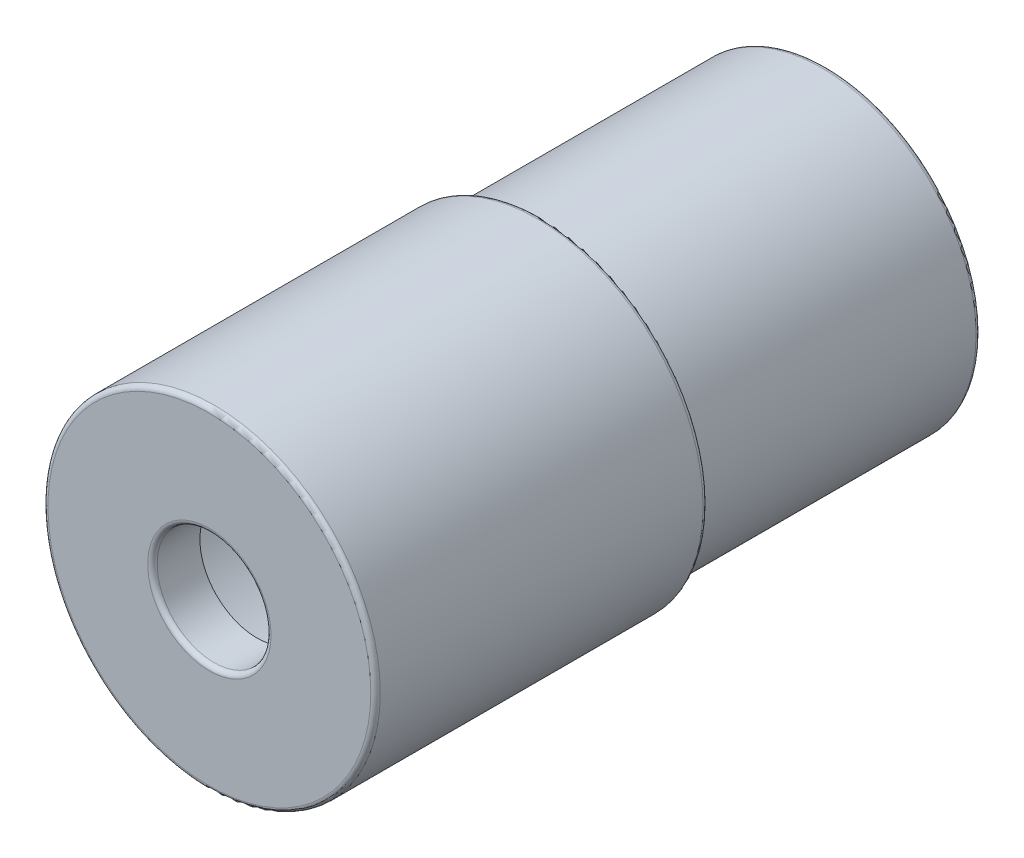
from build123d import *

# Parameters (mm, degrees)
SKETCH1_R           = 17.5
SKETCH1_R_2         = 15
BOSS_EXTRUDE1_DEPTH = 30
SKETCH2_R           = 16.25
SKETCH2_R_2         = 15
BOSS_EXTRUDE2_DEPTH = 30
SKETCH3_R           = 17.5
BOSS_EXTRUDE3_DEPTH = 5
SKETCH4_R           = 6
CUT_EXTRUDE1_DEPTH  = 10
FILLET2_R           = 0.5
FILLET3_R           = 0.5
FILLET4_R           = 0.5


with BuildPart() as part:
    # Sketch1 → Boss-Extrude1 (new body)
    with BuildSketch(Plane.XY):
        Circle(SKETCH1_R)
        Circle(SKETCH1_R_2, mode=Mode.SUBTRACT)
    extrude(amount=-BOSS_EXTRUDE1_DEPTH)

    # Sketch3 → Boss-Extrude3 (add)
    with BuildSketch(Plane.XY):
        Circle(SKETCH3_R)
    extrude(amount=BOSS_EXTRUDE3_DEPTH)

    # Sketch4 → Cut-Extrude1 (cut)
    with BuildSketch(Plane.XY.offset(5)):
        Circle(SKETCH4_R)
    extrude(amount=-CUT_EXTRUDE1_DEPTH, mode=Mode.SUBTRACT)


with BuildPart() as body_2:
    # Sketch2 → Boss-Extrude2 (new body)
    with BuildSketch(Plane(origin=(0, 0, -30), x_dir=(-1, 0, 0), z_dir=(0, 0, -1))):
        Circle(SKETCH2_R)
        with Locations(Location((0, 0, 0), (0, 0, 180))):
            Circle(SKETCH2_R_2, mode=Mode.SUBTRACT)
    extrude(amount=BOSS_EXTRUDE2_DEPTH)

    # Combine1: union part
    add(part.part)

    # Fillet2
    fillet2_edges = [body_2.edges().sort_by_distance(p)[0] for p in [
        (16.25, 0, -30),
    ]]
    fillet(fillet2_edges, radius=FILLET2_R)

    # Fillet3
    fillet3_edges = [body_2.edges().sort_by_distance(p)[0] for p in [
        (-17.5, 0, -30),
        (16.25, 0, -60),
        (-15, 0, -60),
    ]]
    fillet(fillet3_edges, radius=FILLET3_R)

    # Fillet4
    fillet4_edges = [body_2.edges().sort_by_distance(p)[0] for p in [
        (-17.5, 0, 5),
        (-6, 0, 5),
    ]]
    fillet(fillet4_edges, radius=FILLET4_R)


solid = body_2.part
